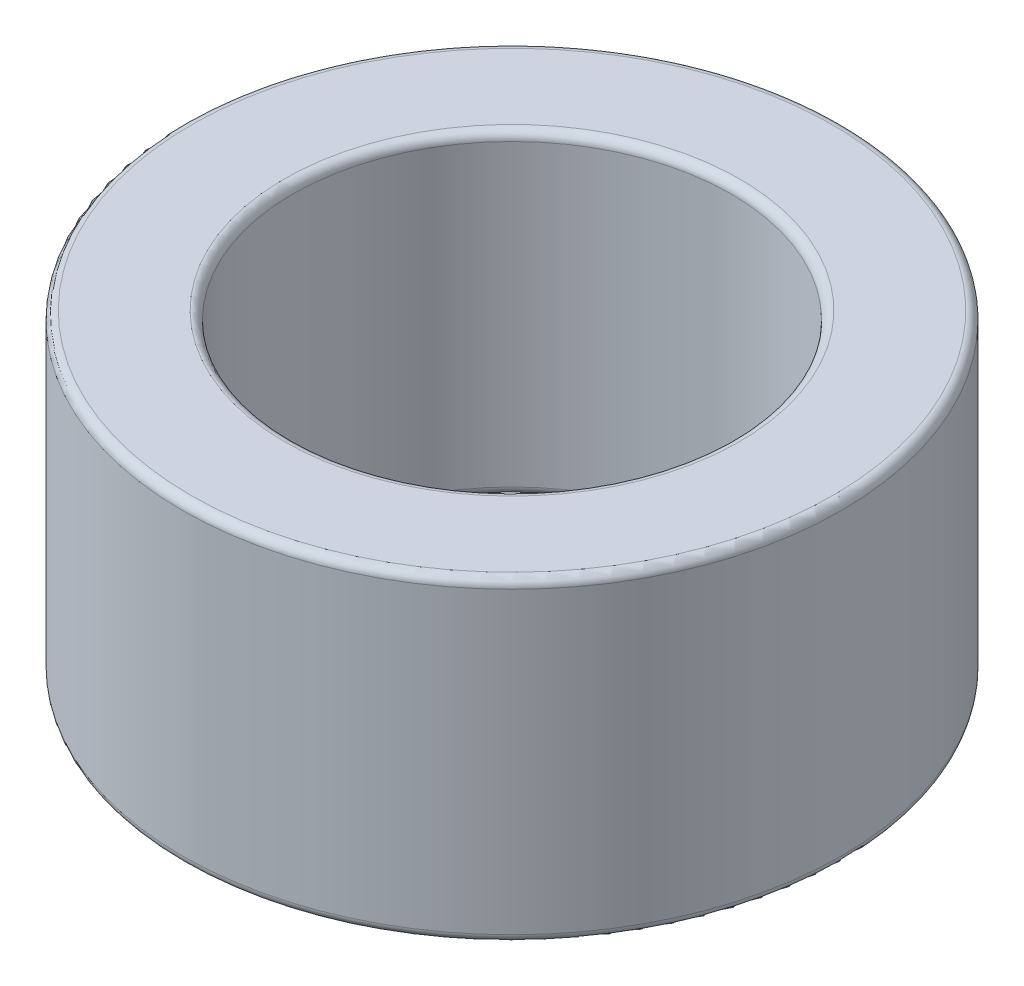
from build123d import *

# Parameters (mm, degrees)
SKETCH_1_R      = 3.8
SKETCH_1_R_2    = 2.525
EXTRUDE_1_DEPTH = 3.65
FILLET_1_R      = 0.1


with BuildPart() as part:
    # Эскиз1 → Бобышка-Вытянуть1 (new body)
    with BuildSketch(Plane(origin=(0, 0, 0), x_dir=(1, 0, 0), z_dir=(0, 1, 0))):
        Circle(SKETCH_1_R)
        Circle(SKETCH_1_R_2, mode=Mode.SUBTRACT)
    extrude(amount=EXTRUDE_1_DEPTH)

    # Скругление1
    fillet_1_edges = [part.edges().sort_by_distance(p)[0] for p in [
        (-3.8, 0, 0),
        (-3.8, 3.65, 0),
        (-2.525, 0, 0),
        (-2.525, 3.65, 0),
    ]]
    fillet(fillet_1_edges, radius=FILLET_1_R)


solid = part.part
